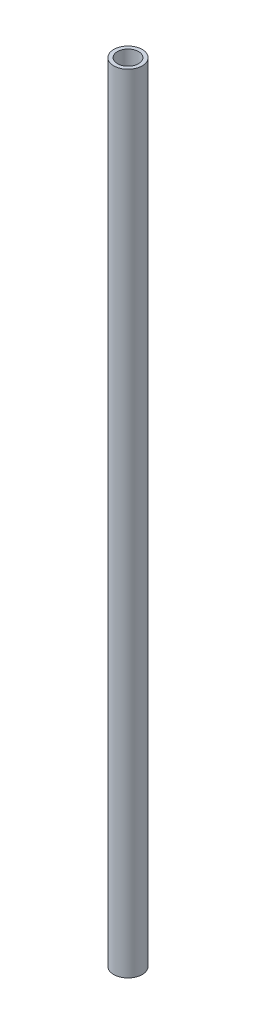
from build123d import *

# Parameters (mm, degrees)
SKETCH1_R           = 10.668
SKETCH1_R_2         = 7.8994
BOSS_EXTRUDE1_DEPTH = 590


with BuildPart() as part:
    # Sketch1 → Boss-Extrude1 (new body)
    with BuildSketch(Plane(origin=(0, 0, 0), x_dir=(1, 0, 0), z_dir=(0, 1, 0))):
        Circle(SKETCH1_R)
        Circle(SKETCH1_R_2, mode=Mode.SUBTRACT)
    extrude(amount=BOSS_EXTRUDE1_DEPTH)


solid = part.part
